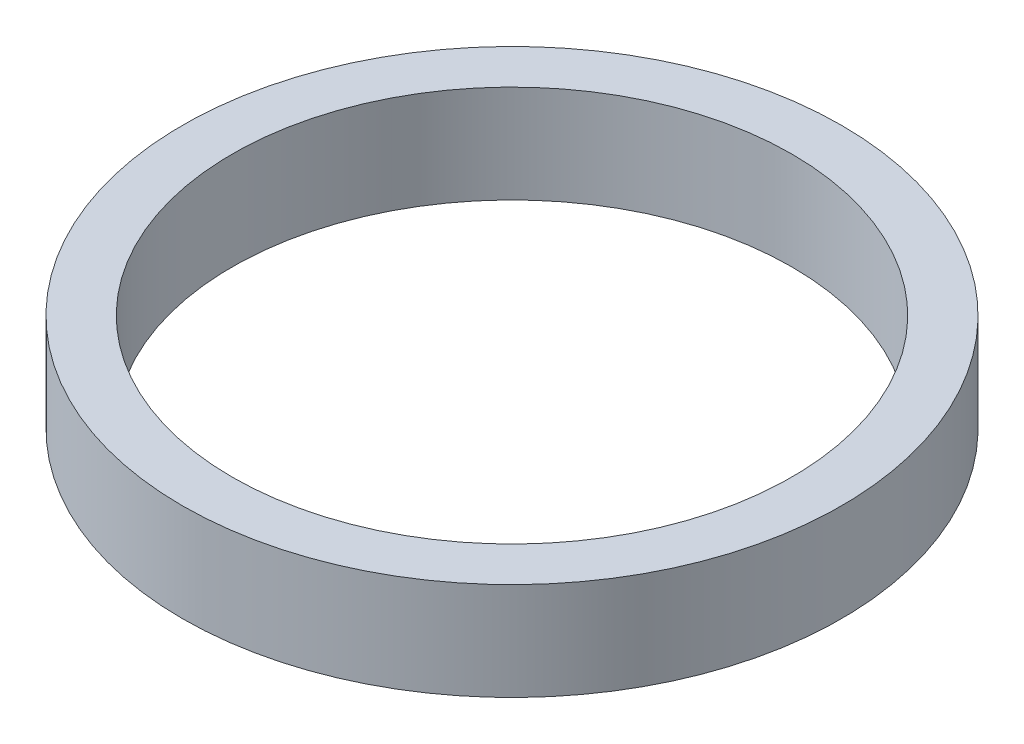
from build123d import *

# Parameters (mm, degrees)
SKETCH1_R           = 19.55
SKETCH1_R_2         = 16.6
BOSS_EXTRUDE1_DEPTH = 5.8


with BuildPart() as part:
    # Sketch1 → Boss-Extrude1 (new body)
    with BuildSketch(Plane(origin=(0, 0, 0), x_dir=(1, 0, 0), z_dir=(0, 1, 0))):
        Circle(SKETCH1_R)
        Circle(SKETCH1_R_2, mode=Mode.SUBTRACT)
    extrude(amount=BOSS_EXTRUDE1_DEPTH)


solid = part.part
